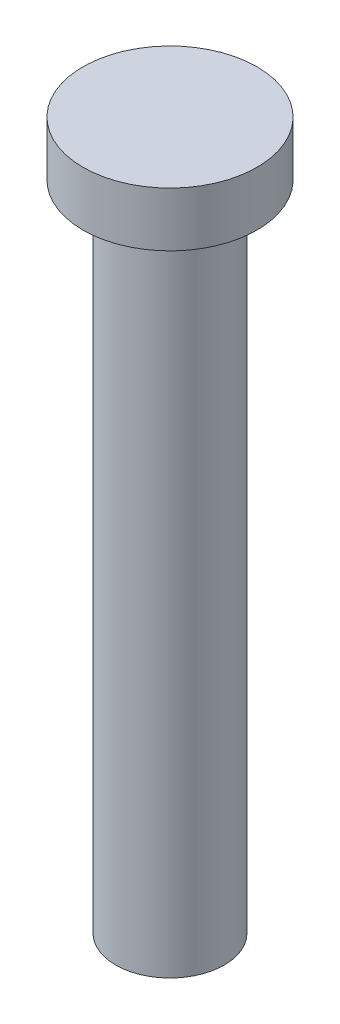
from build123d import *

# Parameters (mm, degrees)
SKETCH1_R           = 2.5
BOSS_EXTRUDE1_DEPTH = 30
SKETCH2_R           = 4
BOSS_EXTRUDE2_DEPTH = 2.5
CHAMFER1_SIZE       = 1


with BuildPart() as part:
    # Sketch1 → Boss-Extrude1 (new body)
    with BuildSketch(Plane(origin=(0, 0, 0), x_dir=(1, 0, 0), z_dir=(0, 1, 0))):
        Circle(SKETCH1_R)
    extrude(amount=BOSS_EXTRUDE1_DEPTH)

    # Sketch2 → Boss-Extrude2 (add)
    with BuildSketch(Plane(origin=(0, 30, 0), x_dir=(1, 0, 0), z_dir=(0, 1, 0))):
        Circle(SKETCH2_R)
    extrude(amount=BOSS_EXTRUDE2_DEPTH)

    # Chamfer1
    chamfer1_edges = [part.edges().sort_by_distance(p)[0] for p in [
        (-2.5, 30, 0),
    ]]
    chamfer(chamfer1_edges, length=CHAMFER1_SIZE)


solid = part.part
